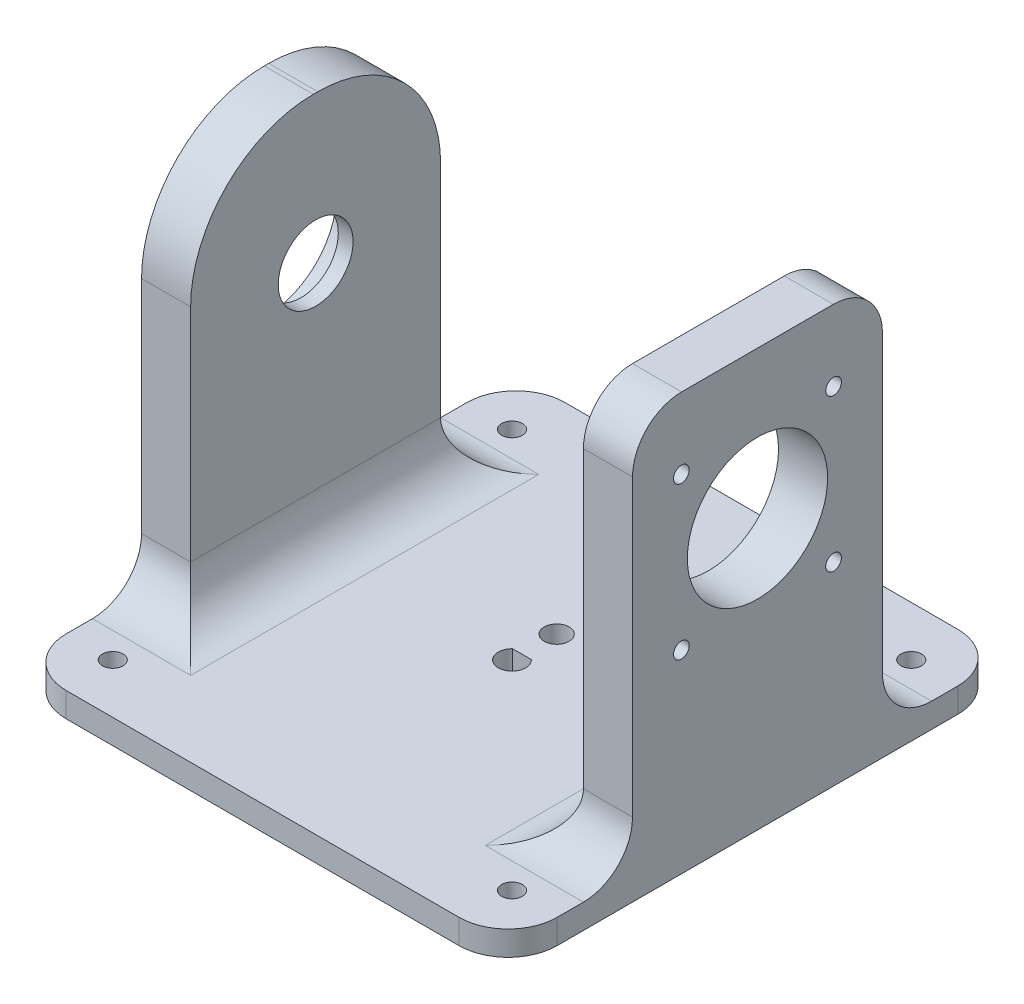
from build123d import *

# Parameters (mm, degrees)
SKETCH2_W             = 10
SKETCH2_H             = 101.6
BOSS_EXTRUDE1_DEPTH   = 80
BOSS_EXTRUDE1_2_DEPTH = 80
SKETCH2_3_W           = 10
SKETCH2_3_H           = 101.6
SKETCH2_3_W_2         = 80
BOSS_EXTRUDE2_DEPTH   = 5
SKETCH3_R             = 14.2875
CUT_EXTRUDE1_DEPTH    = 117
SKETCH4_W             = 25.345740838
SKETCH4_H             = 80
CUT_EXTRUDE2_DEPTH    = 119
FILLET3_R             = 10
FILLET2_R             = 10
SKETCH7_R             = 1.6
CUT_EXTRUDE4_DEPTH    = 21
BOSS_EXTRUDE3_START   = 80
SKETCH8_R             = 14.2875
SKETCH8_R_2           = 7.62
BOSS_EXTRUDE3_DEPTH   = 3
SKETCH9_R             = 2.1
CUT_EXTRUDE5_DEPTH    = 5
CUT_EXTRUDE6_DEPTH    = 10
SKETCH10_R            = 2.54
CUT_EXTRUDE7_DEPTH    = 10
FILLET4_R             = 25


with BuildPart() as part:
    # Sketch2 → Boss-Extrude1 (new body)
    with BuildSketch(Plane(origin=(0, 0, 0), x_dir=(1, 0, 0), z_dir=(0, 1, 0))):
        with Locations((-45, 0)):
            Rectangle(SKETCH2_W, SKETCH2_H)
    extrude(amount=BOSS_EXTRUDE1_DEPTH)



with BuildPart() as body_2:
    # Sketch2 → Boss-Extrude1 2 (new body)
    with BuildSketch(Plane(origin=(0, 0, 0), x_dir=(1, 0, 0), z_dir=(0, 1, 0))):
        with Locations((45, 0)):
            Rectangle(SKETCH2_W, SKETCH2_H)
    extrude(amount=BOSS_EXTRUDE1_2_DEPTH)


with BuildPart() as part_1:
    add(part.part)

    add(body_2.part)  # Boss-Extrude2 merges body 2
    # Sketch2_3 → Boss-Extrude2 (add)
    with BuildSketch(Plane(origin=(0, 0, 0), x_dir=(1, 0, 0), z_dir=(0, 1, 0))):
        with Locations((45, 0)):
            Rectangle(SKETCH2_3_W, SKETCH2_3_H)
        Rectangle(SKETCH2_3_W_2, SKETCH2_3_H)
        with Locations((-45, 0)):
            Rectangle(SKETCH2_3_W, SKETCH2_3_H)
    extrude(amount=-BOSS_EXTRUDE2_DEPTH)

    # Sketch3 → Cut-Extrude1 (cut)
    with BuildSketch(Plane.ZY.offset(50)):
        with Locations((0, 50)):
            Circle(SKETCH3_R)
    extrude(amount=-CUT_EXTRUDE1_DEPTH, mode=Mode.SUBTRACT)

    # Sketch4 → Cut-Extrude2 (cut)
    with BuildSketch(Plane(origin=(50, 0, 0), x_dir=(0, 0, -1), z_dir=(1, 0, 0))):
        with Locations((-38.127129581, 40)):
            Rectangle(SKETCH4_W, SKETCH4_H)
        with Locations((38.127129581, 40)):
            Rectangle(SKETCH4_W, SKETCH4_H)
    extrude(amount=-CUT_EXTRUDE2_DEPTH, mode=Mode.SUBTRACT)

    # Fillet3
    fillet3_edges = [part_1.edges().sort_by_distance(p)[0] for p in [
        (45, 80, -25.454259162),
        (45, 80, 25.454259162),
        (40, 0, 0),
        (-40, 0, 0),
        (-45, 0, 25.454259162),
        (45, 0, 25.454259162),
        (-45, 0, -25.454259162),
        (45, 0, -25.454259162),
    ]]
    fillet(fillet3_edges, radius=FILLET3_R)

    # Fillet2
    fillet2_edges = [part_1.edges().sort_by_distance(p)[0] for p in [
        (50, -2.5, -50.8),
        (50, -2.5, 50.8),
        (-50, -2.5, 50.8),
        (-50, -2.5, -50.8),
    ]]
    fillet(fillet2_edges, radius=FILLET2_R)

    # Sketch7 → Cut-Extrude4 (cut)
    with BuildSketch(Plane(origin=(50, 0, 0), x_dir=(0, 0, -1), z_dir=(1, 0, 0))):
        with Locations((-15.5, 65.5)):
            Circle(SKETCH7_R)
        with Locations((15.5, 65.5)):
            Circle(SKETCH7_R)
        with Locations((15.5, 34.5)):
            Circle(SKETCH7_R)
        with Locations((-15.5, 34.5)):
            Circle(SKETCH7_R)
    extrude(amount=-CUT_EXTRUDE4_DEPTH, mode=Mode.SUBTRACT)

    # Sketch8 → Boss-Extrude3 (add)
    with BuildSketch(Plane.ZY.offset(-40).offset(BOSS_EXTRUDE3_START)):
        with Locations((0, 50)):
            Circle(SKETCH8_R)
        with Locations((0, 50)):
            Circle(SKETCH8_R_2, mode=Mode.SUBTRACT)
    extrude(amount=BOSS_EXTRUDE3_DEPTH)

    # Sketch9 → Cut-Extrude5 (cut)
    with BuildSketch(Plane.XZ.offset(5)):
        with Locations((-40.66, 40.66)):
            Circle(SKETCH9_R)
        with Locations((40.66, 40.66)):
            Circle(SKETCH9_R)
        with Locations((-40.66, -40.66)):
            Circle(SKETCH9_R)
        with Locations((40.66, -40.66)):
            Circle(SKETCH9_R)
    extrude(amount=-CUT_EXTRUDE5_DEPTH, mode=Mode.SUBTRACT)

    # Sketch5 → Cut-Extrude6 (cut)
    with BuildSketch(Plane(origin=(0, 0, 0), x_dir=(1, 0, 0), z_dir=(0, 1, 0))):
        with BuildLine():
            Line((-1.917657947, 2.032), (1.917657947, 2.032))
            ThreePointArc((1.917657947, 2.032), (0, -2.794), (-1.917657947, 2.032))
        make_face()
    extrude(amount=-CUT_EXTRUDE6_DEPTH, mode=Mode.SUBTRACT)

    # Sketch10 → Cut-Extrude7 (cut)
    with BuildSketch(Plane(origin=(0, 0, 0), x_dir=(1, 0, 0), z_dir=(0, 1, 0))):
        with Locations((0, 9.099794366)):
            Circle(SKETCH10_R)
    extrude(amount=-CUT_EXTRUDE7_DEPTH, mode=Mode.SUBTRACT)

    # Fillet4
    fillet4_edges = [part_1.edges().sort_by_distance(p)[0] for p in [
        (-45, 80, 25.454259162),
        (-45, 80, -25.454259162),
    ]]
    fillet(fillet4_edges, radius=FILLET4_R)


solid = part_1.part
